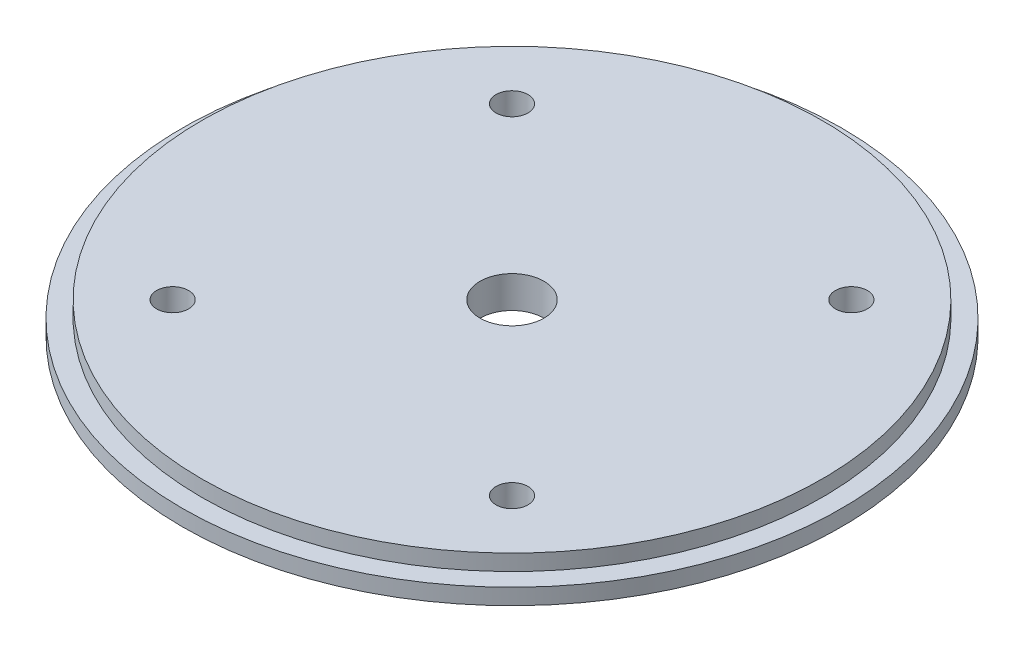
from build123d import *

# Parameters (mm, degrees)
SKETCH2_R                   = 65.405
BOSS_EXTRUDE1_DEPTH         = 6.35
SKETCH4_R                   = 65.405
SKETCH4_R_2                 = 61.595
CUT_EXTRUDE1_DEPTH          = 3.175
F_1_4_0_25_DIAMETER_HOLE1_D = 6.35
F_1_2_0_5_DIAMETER_HOLE1_D  = 12.7
SKETCH9_R                   = 6.0325
CUT_EXTRUDE2_DEPTH          = 1.5875


with BuildPart() as part:
    # Sketch2 → Boss-Extrude1 (new body)
    with BuildSketch(Plane(origin=(0, 0, 0), x_dir=(1, 0, 0), z_dir=(0, 1, 0))):
        Circle(SKETCH2_R)
    extrude(amount=BOSS_EXTRUDE1_DEPTH)

    # Sketch4 → Cut-Extrude1 (cut)
    with BuildSketch(Plane(origin=(0, 6.35, 0), x_dir=(1, 0, 0), z_dir=(0, 1, 0))):
        Circle(SKETCH4_R)
        Circle(SKETCH4_R_2, mode=Mode.SUBTRACT)
    extrude(amount=-CUT_EXTRUDE1_DEPTH, mode=Mode.SUBTRACT)

    # 1/4 (0.25) Diameter Hole1 (through all)
    with Locations(Plane(origin=(0, 6.35, 0), x_dir=(1, 0, 0), z_dir=(0, 1, 0))):
        with Locations((-33.675960454, 33.675960454), (-33.675960454, -33.675960454), (33.675960454, 33.675960454), (33.675960454, -33.675960454)):
            Hole(F_1_4_0_25_DIAMETER_HOLE1_D / 2)

    # 1/2 (0.5) Diameter Hole1 (through all)
    with Locations(Plane(origin=(0, 6.35, 0), x_dir=(1, 0, 0), z_dir=(0, 1, 0))):
        with Locations((0, 0)):
            Hole(F_1_2_0_5_DIAMETER_HOLE1_D / 2)

    # Sketch9 → Cut-Extrude2 (cut)
    with BuildSketch(Plane.XZ):
        with Locations((-33.675960454, 33.675960454)):
            Circle(SKETCH9_R)
        with Locations((33.675960454, 33.675960454)):
            Circle(SKETCH9_R)
        with Locations((33.675960454, -33.675960454)):
            Circle(SKETCH9_R)
        with Locations((-33.675960454, -33.675960454)):
            Circle(SKETCH9_R)
    extrude(amount=-CUT_EXTRUDE2_DEPTH, mode=Mode.SUBTRACT)


solid = part.part
